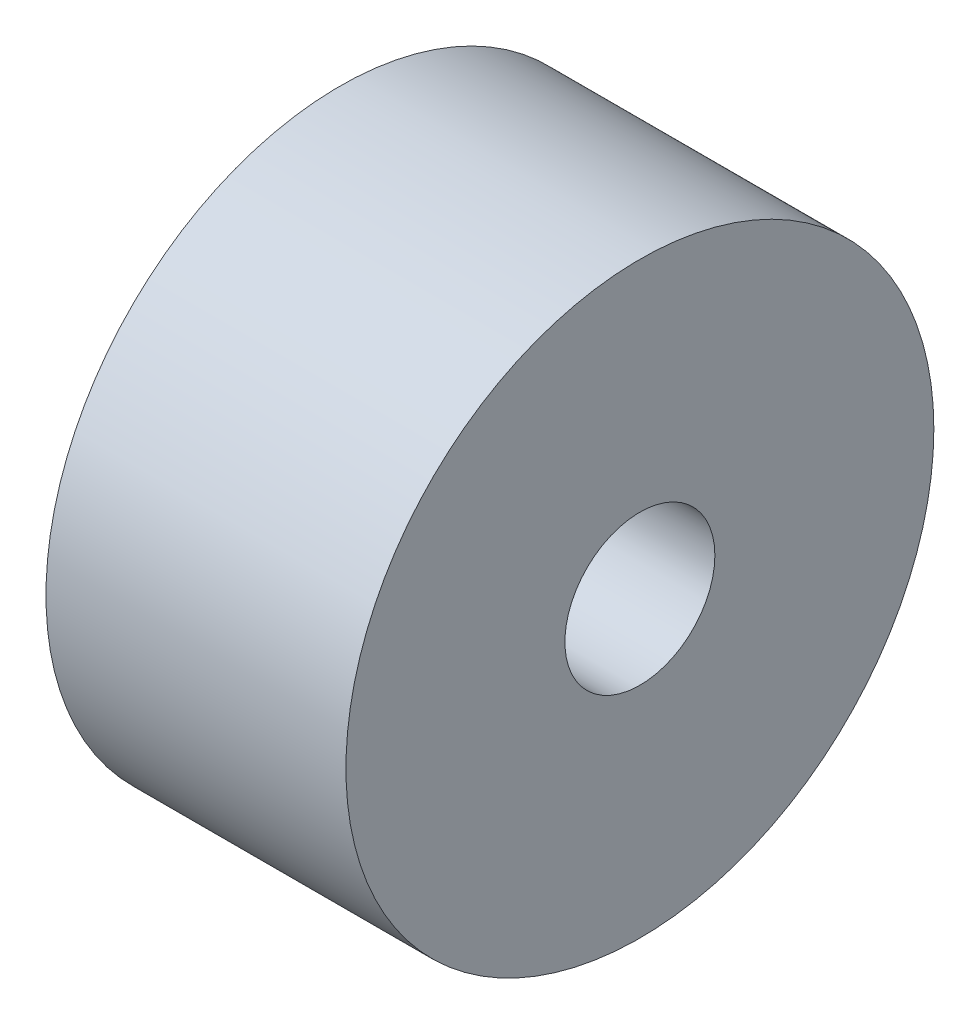
from build123d import *

# Parameters (mm, degrees)
SKETCH1_R           = 49
SKETCH1_R_2         = 12.5
BOSS_EXTRUDE1_DEPTH = 50


with BuildPart() as part:
    # Sketch1 → Boss-Extrude1 (new body)
    with BuildSketch(Plane(origin=(0, 0, 0), x_dir=(0, 0, -1), z_dir=(1, 0, 0))):
        Circle(SKETCH1_R)
        Circle(SKETCH1_R_2, mode=Mode.SUBTRACT)
    extrude(amount=BOSS_EXTRUDE1_DEPTH)


solid = part.part
